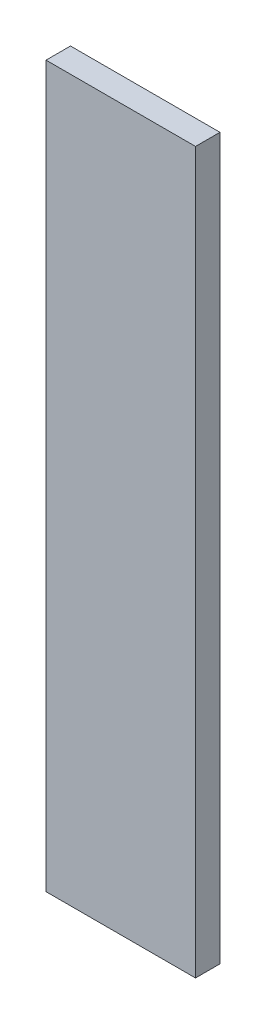
from build123d import *

# Parameters (mm, degrees)
SKETCH1_W           = 110
SKETCH1_H           = 530
BOSS_EXTRUDE1_DEPTH = 18


with BuildPart() as part:
    # Sketch1 → Boss-Extrude1 (new body)
    with BuildSketch(Plane.XY):
        Rectangle(SKETCH1_W, SKETCH1_H)
    extrude(amount=BOSS_EXTRUDE1_DEPTH)


solid = part.part
